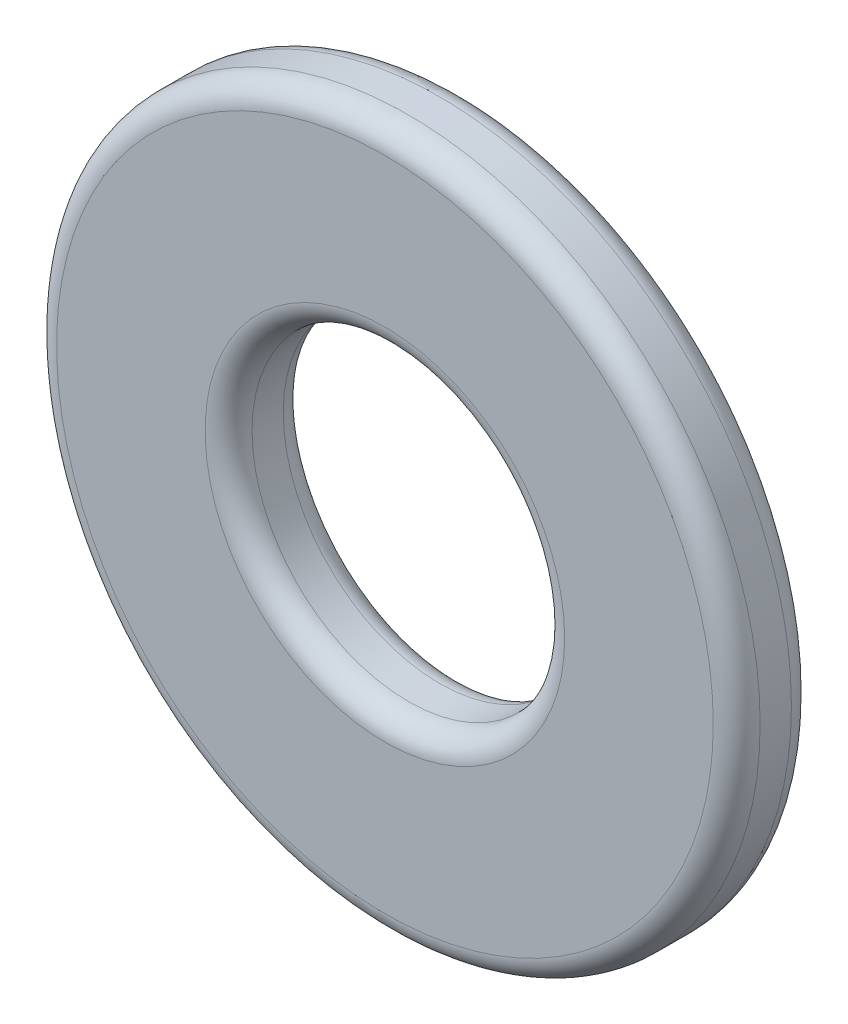
from build123d import *

# Parameters (mm, degrees)
SKETCH1_R      = 2.25
SKETCH1_R_2    = 1
EXTRUDE1_DEPTH = 0.25
FILLET1_R      = 0.15


with BuildPart() as part:
    # Sketch1 → Extrude1 (new body, symmetric)
    with BuildSketch(Plane.XY):
        Circle(SKETCH1_R)
        Circle(SKETCH1_R_2, mode=Mode.SUBTRACT)
    extrude(amount=EXTRUDE1_DEPTH, both=True)

    # Fillet1
    fillet1_edges = [part.edges().sort_by_distance(p)[0] for p in [
        (-2.25, 0, -0.25),
        (-2.25, 0, 0.25),
        (-1, 0, -0.25),
        (-1, 0, 0.25),
    ]]
    fillet(fillet1_edges, radius=FILLET1_R)


solid = part.part
